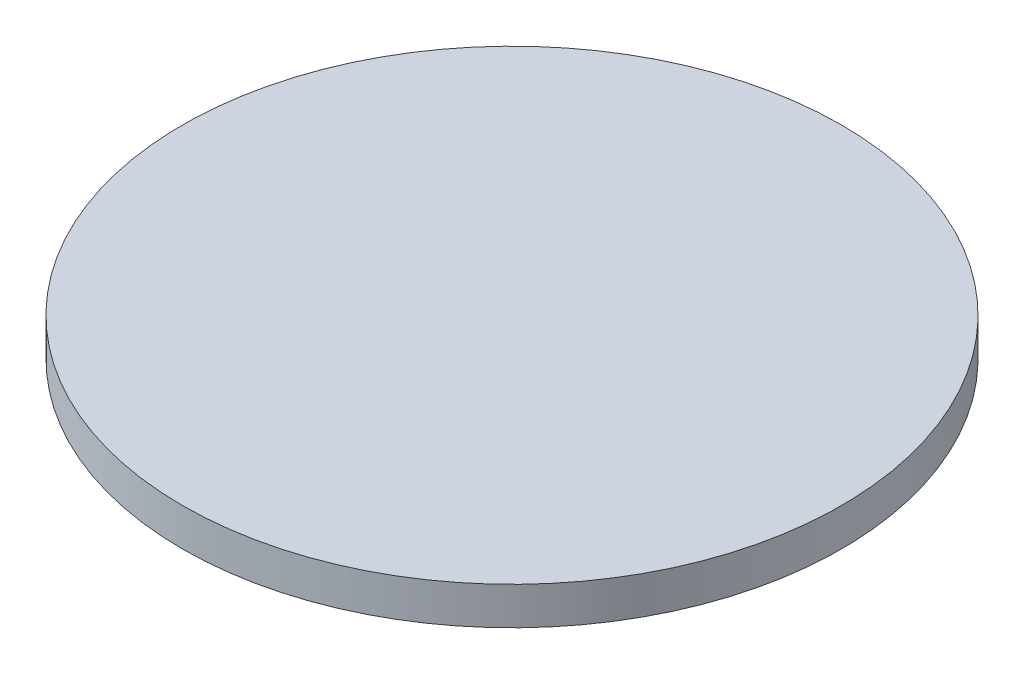
from build123d import *

# Parameters (mm, degrees)
SKETCH1_R           = 22.225
BOSS_EXTRUDE1_DEPTH = 2.54


with BuildPart() as part:
    # Sketch1 → Boss-Extrude1 (new body)
    with BuildSketch(Plane(origin=(0, 0, 0), x_dir=(1, 0, 0), z_dir=(0, 1, 0))):
        Circle(SKETCH1_R)
    extrude(amount=BOSS_EXTRUDE1_DEPTH)


solid = part.part
